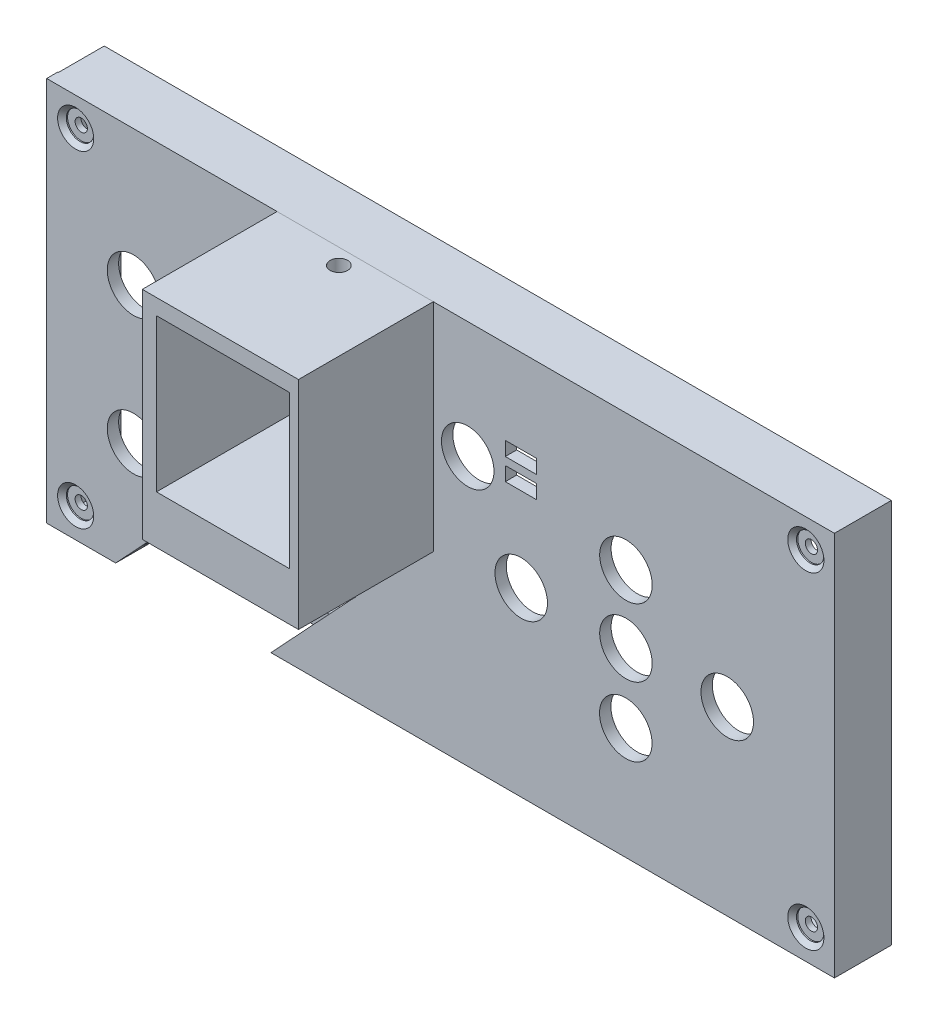
from build123d import *

# Parameters (mm, degrees)
SKETCH1_W                                   = 114.3
SKETCH1_H                                   = 55.88
BOSS_EXTRUDE1_DEPTH                         = 1.651
SKETCH2_R                                   = 3.81
SKETCH2_W                                   = 4.5212
SKETCH2_H                                   = 2.032
CUT_EXTRUDE2_DEPTH                          = 2.651
SKETCH3_W                                   = 22.661984054
SKETCH3_H                                   = 31.417286438
BOSS_EXTRUDE2_DEPTH                         = 19.558
SKETCH7_W                                   = 19.271471292
SKETCH7_H                                   = 22.14393761
CUT_EXTRUDE5_DEPTH                          = 20.558
SKETCH8_W                                   = 114.20462943
SKETCH8_H                                   = 55.88
SKETCH8_W_2                                 = 109.31537057
SKETCH8_H_2                                 = 50.990741141
BOSS_EXTRUDE4_DEPTH                         = 6.604
SKETCH9_R                                   = 1.27
CUT_EXTRUDE6_DEPTH                          = 2.032
SKETCH10_W                                  = 22.51976533
SKETCH10_H                                  = 4.967150309
CUT_EXTRUDE7_DEPTH                          = 12.7
CBORE_FOR_0_BINDING_HEAD_MACHINE_SC_2_COUNT = 2
CBORE_FOR_0_BINDING_HEAD_MACHINE_SC_2_PITCH = 47.42542097
CBORE_FOR_0_BINDING_HEAD_MACHINE_SC_3_COUNT = 2
CBORE_FOR_0_BINDING_HEAD_MACHINE_SC_3_PITCH = 105.943027259
CBORE_FOR_0_BINDING_HEAD_MACHINE_SC_4_COUNT = 2
CBORE_FOR_0_BINDING_HEAD_MACHINE_SC_4_PITCH = 116.073664451


with BuildPart() as part:
    # Sketch1 → Boss-Extrude1 (new body)
    with BuildSketch(Plane.XY):
        with Locations((3000.347199497, 13522.309097574)):
            Rectangle(SKETCH1_W, SKETCH1_H)
    extrude(amount=BOSS_EXTRUDE1_DEPTH)

    # Sketch2 → Cut-Extrude2 (cut, through all)
    with BuildSketch(Plane.XY):
        with Locations((3027.248279136, 13530.507714547)):
            Circle(SKETCH2_R)
        with Locations((3012.050482156, 13520.653009344)):
            Circle(SKETCH2_R)
        with Locations((3027.248279136, 13520.653009344)):
            Circle(SKETCH2_R)
        with Locations((3041.941037356, 13520.653009344)):
            Circle(SKETCH2_R)
        with Locations((3027.222481478, 13510.622681626)):
            Circle(SKETCH2_R)
        with Locations((3004.288363872, 13533.330573619)):
            Circle(SKETCH2_R)
        with Locations((2955.799681977, 13530.583123085)):
            Circle(SKETCH2_R)
        with Locations((2955.799681977, 13510.673284723)):
            Circle(SKETCH2_R)
        with Locations((3012.001784077, 13533.872650423)):
            Rectangle(SKETCH2_W, SKETCH2_H)
        with Locations((3012.001784077, 13537.034507661)):
            Rectangle(SKETCH2_W, SKETCH2_H)
        Polygon((2997.958816699, 13534.888650423), (2997.958816699, 13525.823845972), (2978.687345407, 13525.823845972), (2978.687345407, 13547.804468145), (2997.958816699, 13547.804468145), align=None)
        Polygon((2975.733076321, 13518.489618725), (2953.213310991, 13494.369097574), (2975.733076321, 13494.369097574), (2987.379412932, 13506.843282115), (2987.998983464, 13507.462852647), (2976.352646854, 13519.109189258), align=None)
    extrude(amount=CUT_EXTRUDE2_DEPTH, mode=Mode.SUBTRACT)

    # Sketch8 → Boss-Extrude4 (add)
    with BuildSketch(Plane(origin=(0, 0, 0), x_dir=(-1, 0, 0), z_dir=(0, 0, -1))):
        with Locations((-3000.394884782, 13522.309097574)):
            Rectangle(SKETCH8_W, SKETCH8_H)
        with Locations((-3000.394884782, 13522.309097574)):
            Rectangle(SKETCH8_W_2, SKETCH8_H_2, mode=Mode.SUBTRACT)
    extrude(amount=BOSS_EXTRUDE4_DEPTH)

    # Sketch10 → Cut-Extrude7 (cut, along a direction that is not the sketch's normal)
    with BuildSketch(Plane.XZ.offset(-13494.369097574)):
        with Locations((2964.473193656, -2.483575154)):
            Rectangle(SKETCH10_W, SKETCH10_H)
    extrude(amount=-CUT_EXTRUDE7_DEPTH, dir=(-0.682436128, -0.730945231, 0), mode=Mode.SUBTRACT)

    # Sketch12 → CBORE for #0 Binding Head Machine Screw1 (revolve, cut)
    with BuildSketch(Plane(origin=(3053.346374668, 13546.090548366, 1.651), x_dir=(0, -1, 0), z_dir=(1, 0, 0))):
        Polygon((0, 0), (0, 8.255025), (0.889, 8.255025), (0.889, 0.8128), (1.98501, 0.8128), (1.98501, 0.635), (2.62001, 0), align=None)
    cbore_for_0_binding_head_machine_screw1 = revolve(axis=Axis((3053.346374668, 13546.090548366, 8.001), (0, 0, -1)), mode=Mode.SUBTRACT)

    # CBORE for _0 Binding Head Machine Sc 2: CBORE for #0 Binding Head Machine Screw1 ×2
    with Locations(*[(0, -i * CBORE_FOR_0_BINDING_HEAD_MACHINE_SC_2_PITCH, 0) for i in range(1, CBORE_FOR_0_BINDING_HEAD_MACHINE_SC_2_COUNT)]):
        add(cbore_for_0_binding_head_machine_screw1, mode=Mode.SUBTRACT)

    # CBORE for _0 Binding Head Machine Sc 3: CBORE for #0 Binding Head Machine Screw1 ×2
    with Locations(*[(-i * CBORE_FOR_0_BINDING_HEAD_MACHINE_SC_3_PITCH, 0, 0) for i in range(1, CBORE_FOR_0_BINDING_HEAD_MACHINE_SC_3_COUNT)]):
        add(cbore_for_0_binding_head_machine_screw1, mode=Mode.SUBTRACT)

    # CBORE for _0 Binding Head Machine Sc 4: CBORE for #0 Binding Head Machine Screw1 ×2
    with Locations(*[Vector(-0.912722345, -0.408580372, 0) * (i * CBORE_FOR_0_BINDING_HEAD_MACHINE_SC_4_PITCH) for i in range(1, CBORE_FOR_0_BINDING_HEAD_MACHINE_SC_4_COUNT)]):
        add(cbore_for_0_binding_head_machine_screw1, mode=Mode.SUBTRACT)


with BuildPart() as body_2:
    # Sketch3 → Boss-Extrude2 (new body)
    with BuildSketch(Plane.XY.offset(1.651)):
        with Locations((2987.961017002, 13534.540454355)):
            Rectangle(SKETCH3_W, SKETCH3_H)
    extrude(amount=BOSS_EXTRUDE2_DEPTH)

    # Sketch7 → Cut-Extrude5 (cut, through all)
    with BuildSketch(Plane(origin=(0, 0, 1.651), x_dir=(-1, 0, 0), z_dir=(0, 0, -1))):
        with Locations((-2988.323081053, 13536.895814777)):
            Rectangle(SKETCH7_W, SKETCH7_H)
    extrude(amount=-CUT_EXTRUDE5_DEPTH, mode=Mode.SUBTRACT)

    # Sketch9 → Cut-Extrude6 (cut)
    with BuildSketch(Plane(origin=(0, 13550.249097574, 0), x_dir=(1, 0, 0), z_dir=(0, 1, 0))):
        with Locations((2987.885210123, -3.939502026)):
            Circle(SKETCH9_R)
    extrude(amount=-CUT_EXTRUDE6_DEPTH, mode=Mode.SUBTRACT)


solid = Compound([part.part, body_2.part])
